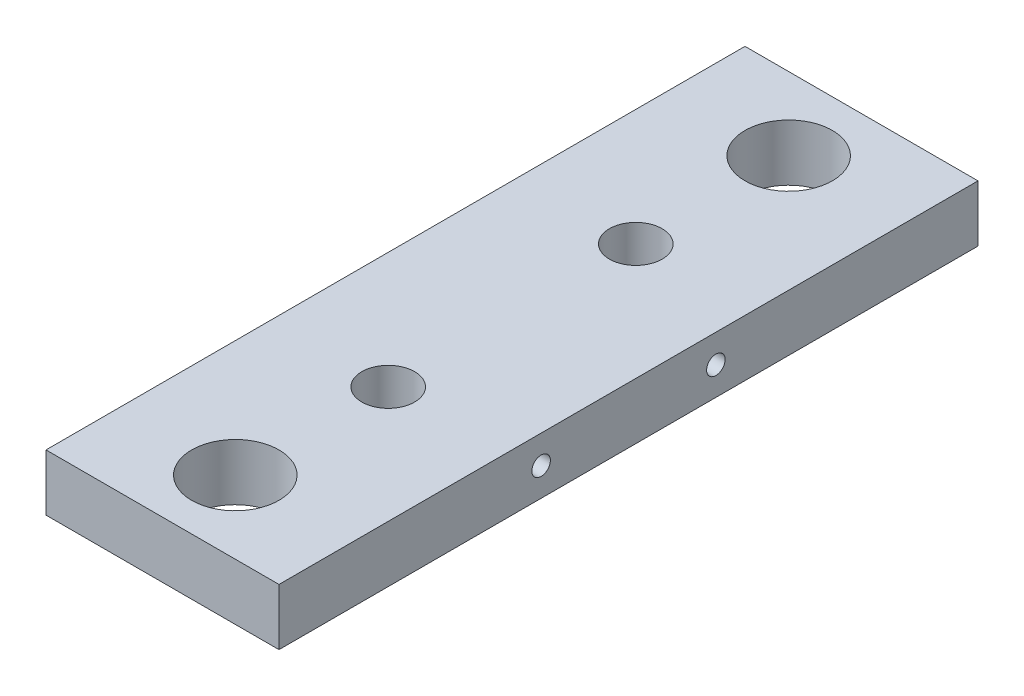
from build123d import *

# Parameters (mm, degrees)
SKETCH1_W                       = 50.8
SKETCH1_H                       = 152.4
EXTRUDE1_DEPTH                  = 6.1595
CUT_EXTRUDE1_REACH              = 14.319
SKETCH2_R                       = 9.525
F_1_2_20_TAPPED_HOLE1_D         = 11.50874
F_1_2_20_TAPPED_HOLE1_DEPTH     = 12.319
F_10_32_TAPPED_HOLE1_AT_2_COUNT = 2
F_10_32_TAPPED_HOLE1_AT_2_PITCH = 38.1


with BuildPart() as part:
    # Sketch1 → Extrude1 (new body, symmetric)
    with BuildSketch(Plane(origin=(0, 0, 0), x_dir=(1, 0, 0), z_dir=(0, 1, 0))):
        Rectangle(SKETCH1_W, SKETCH1_H)
    extrude(amount=EXTRUDE1_DEPTH, both=True)

    # Sketch2 → Cut-Extrude1 (cut, up to next)
    with BuildSketch(Plane(origin=(0, 6.1595, 0), x_dir=(-1, 0, 0), z_dir=(0, 1, 0)), mode=Mode.PRIVATE) as cut_extrude1_sk1:
        with Locations((0, -60.325)):
            Circle(SKETCH2_R)
    cut_extrude1_tool1 = extrude(cut_extrude1_sk1.sketch, amount=-CUT_EXTRUDE1_REACH, mode=Mode.PRIVATE) & part.part
    add(cut_extrude1_tool1.solids().sort_by_distance((0, 6.1595, -60.325))[0], mode=Mode.SUBTRACT)
    # Sketch2 → Cut-Extrude1 (cut, up to next)
    with BuildSketch(Plane(origin=(0, 6.1595, 0), x_dir=(-1, 0, 0), z_dir=(0, 1, 0)), mode=Mode.PRIVATE) as cut_extrude1_sk2:
        with Locations((0, 60.325)):
            Circle(SKETCH2_R)
    cut_extrude1_tool2 = extrude(cut_extrude1_sk2.sketch, amount=-CUT_EXTRUDE1_REACH, mode=Mode.PRIVATE) & part.part
    add(cut_extrude1_tool2.solids().sort_by_distance((0, 6.1595, 60.325))[0], mode=Mode.SUBTRACT)

    # 1/2-20 Tapped Hole1
    with Locations(Plane(origin=(0, 6.1595, 0), x_dir=(-1, 0, 0), z_dir=(0, 1, 0))):
        with Locations((0, -26.9875), (0, 26.9875)):
            Hole(F_1_2_20_TAPPED_HOLE1_D / 2, depth=F_1_2_20_TAPPED_HOLE1_DEPTH)

    # Sketch10 → #10-32 Tapped Hole1 (revolve, cut)
    with BuildSketch(Plane(origin=(25.4, 0, 19.05), x_dir=(0, 0, -1), z_dir=(0, 1, 0))):
        Polygon((0, 0), (0, 14.827717848), (2.0193, 13.6144), (2.0193, 0), align=None)
    f_10_32_tapped_hole1 = revolve(axis=Axis((31.75, 0, 19.05), (-1, 0, 0)), mode=Mode.SUBTRACT)

    # #10-32 Tapped Hole1 at 2: #10-32 Tapped Hole1 ×2
    with Locations(*[(0, 0, -i * F_10_32_TAPPED_HOLE1_AT_2_PITCH) for i in range(1, F_10_32_TAPPED_HOLE1_AT_2_COUNT)]):
        add(f_10_32_tapped_hole1, mode=Mode.SUBTRACT)

    # Mirror1: #10-32 Tapped Hole1 across plane
    add(f_10_32_tapped_hole1.mirror(Plane(origin=(0, 0, 0), x_dir=(0, 0, 1), z_dir=(1, 0, 0))), mode=Mode.SUBTRACT)

    # Mirror1 copy 1 sketch → Mirror1 copy 1 (revolve, cut)
    with BuildSketch(Plane(origin=(-25.4, 0, -19.05), x_dir=(0, 0, -1), z_dir=(0, 1, 0))):
        Polygon((0, 0), (0, -14.827717848), (2.0193, -13.6144), (2.0193, 0), align=None)
    revolve(axis=Axis((-31.75, 0, -19.05), (-1, 0, 0)), mode=Mode.SUBTRACT)


solid = part.part
